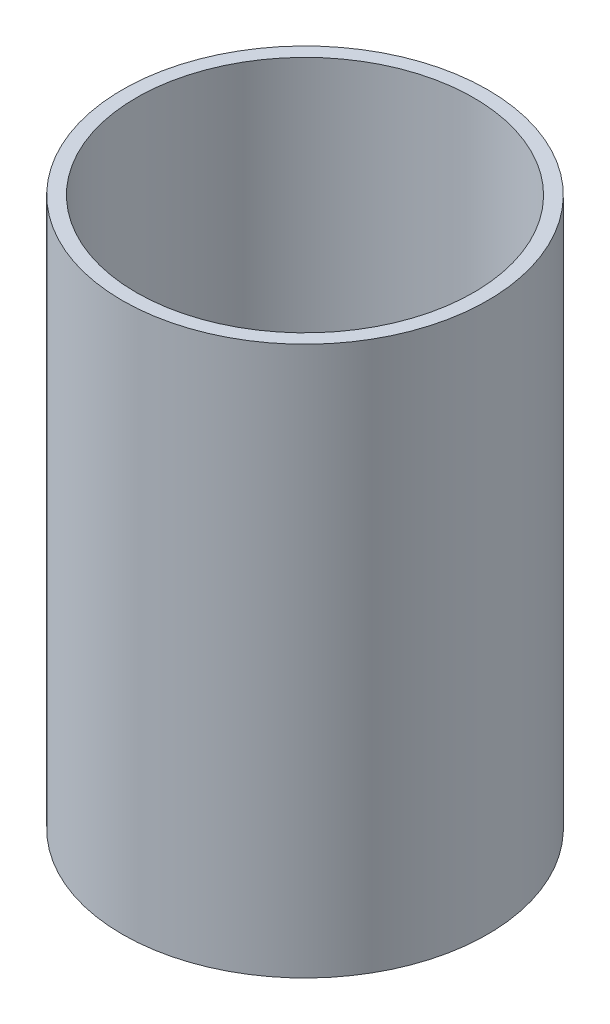
from build123d import *

# Parameters (mm, degrees)
SKETCH1_W = 0.7874
SKETCH1_H = 30.988


with BuildPart() as part:
    # Sketch1 → Revolve1 (revolve)
    with BuildSketch(Plane.XY):
        with Locations((9.9187, 15.494)):
            Rectangle(SKETCH1_W, SKETCH1_H)
    revolve(axis=Axis((0, 0, 0), (0, 1, 0)))


solid = part.part
